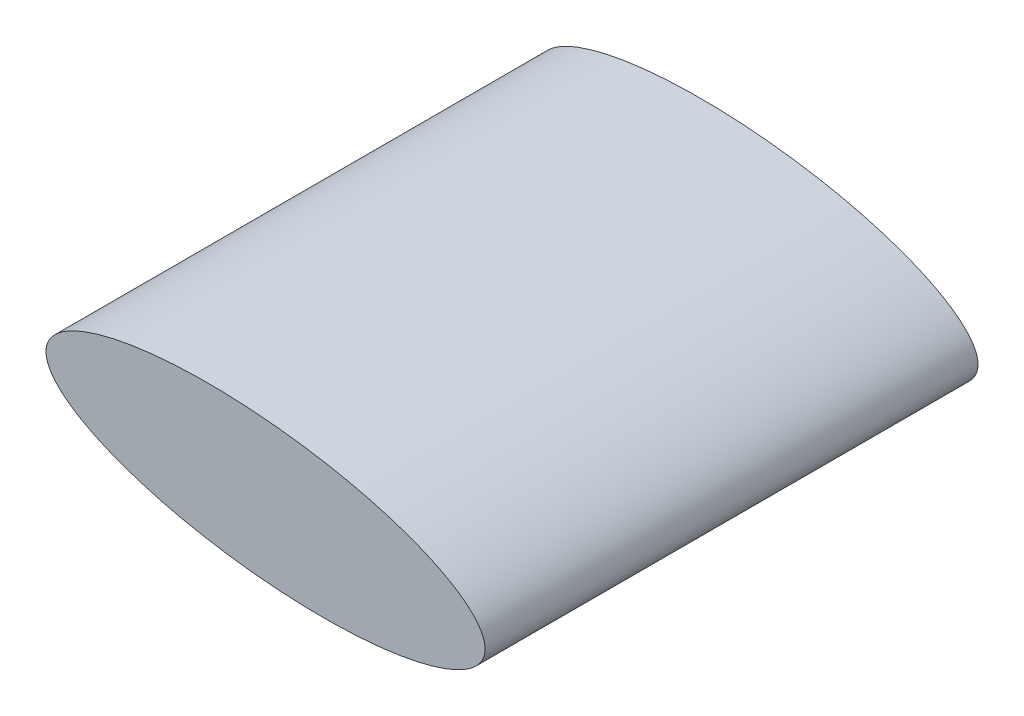
from build123d import *

# Parameters (mm, degrees)
SKETCH1_RX          = 0.246
SKETCH1_RY          = 0.078
BOSS_EXTRUDE1_DEPTH = 0.55


with BuildPart() as part:
    # Sketch1 → Boss-Extrude1 (new body)
    with BuildSketch(Plane(origin=(0, 0, -1.175), x_dir=(-1, 0, 0), z_dir=(0, 0, -1))):
        with Locations(Location((0, 0), (0, 0, -174.474894898))):
            Ellipse(SKETCH1_RX, SKETCH1_RY)
    extrude(amount=-BOSS_EXTRUDE1_DEPTH)


solid = part.part
